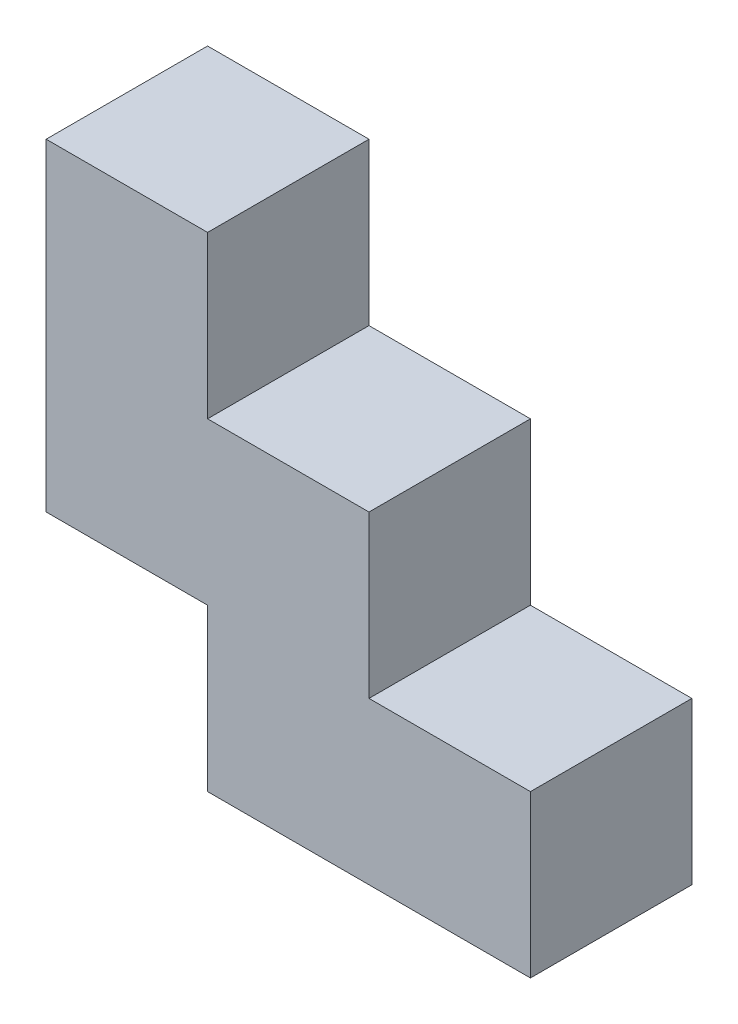
from build123d import *

# Parameters (mm, degrees)
BOSS_EXTRUDE1_DEPTH = 25.4


with BuildPart() as part:
    # Sketch1 → Boss-Extrude1 (new body)
    with BuildSketch(Plane.XY):
        Polygon((76.2, 0), (76.2, 25.4), (50.8, 25.4), (50.8, 50.8), (25.4, 50.8), (25.4, 76.2), (0, 76.2), (0, 25.4), (25.4, 25.4), (25.4, 0), (50.8, 0), align=None)
    extrude(amount=BOSS_EXTRUDE1_DEPTH)


solid = part.part
